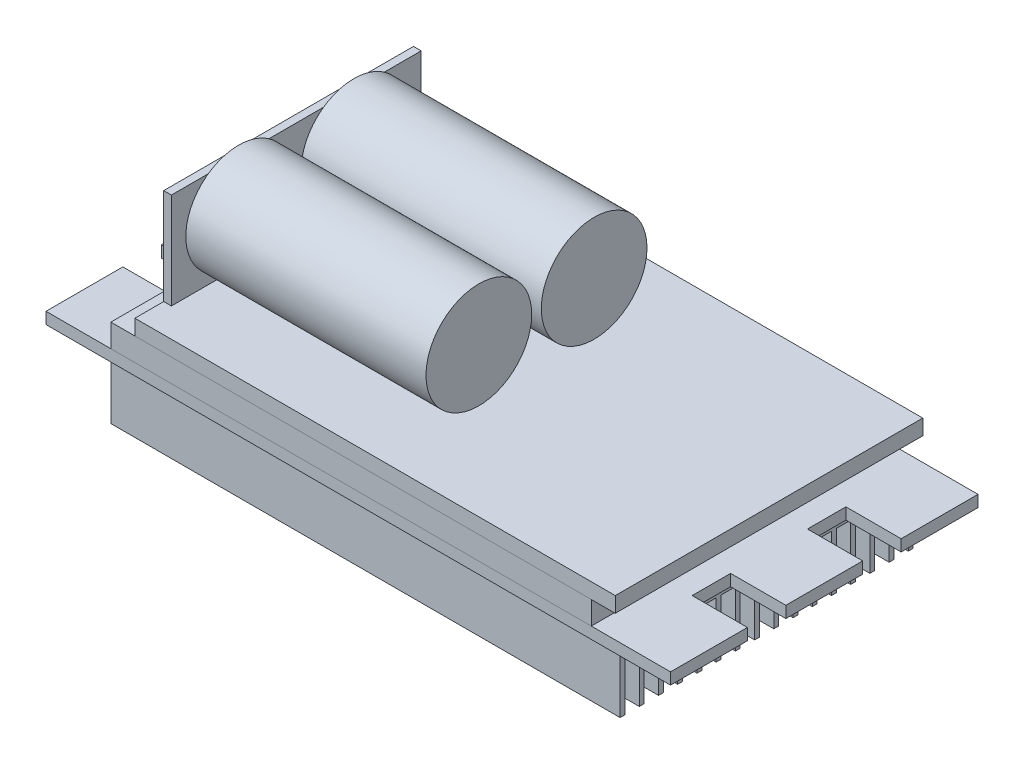
from build123d import *

# Parameters (mm, degrees)
BOSS_EXTRUDE1_DEPTH   = 1.2
SKETCH2_W             = 50
SKETCH2_H             = 32
BOSS_EXTRUDE2_DEPTH   = 2.4
SKETCH3_W             = 50
SKETCH3_H             = 32
BOSS_EXTRUDE3_DEPTH   = 1.6
SKETCH4_W             = 0.8
SKETCH4_H             = 26
BOSS_EXTRUDE4_DEPTH   = 10
SKETCH5_R             = 5.5
BOSS_EXTRUDE6_DEPTH   = 25
BOSS_EXTRUDE6_2_DEPTH = 25
SKETCH6_W             = 53
SKETCH6_H             = 30.5
BOSS_EXTRUDE7_DEPTH   = 6.3
CUT_EXTRUDE7_DEPTH    = 60


with BuildPart() as part:
    # Sketch1 → Boss-Extrude1 (new body)
    with BuildSketch(Plane(origin=(0, 0, 0), x_dir=(1, 0, 0), z_dir=(0, 1, 0))):
        Polygon((-26.75, 16), (-32.5, 16), (-32.5, 8), (-26.75, 8), (-26.75, 4), (-32.5, 4), (-32.5, -4), (-26.75, -4), (-26.75, -8), (-32.5, -8), (-32.5, -16), (-26.75, -16), (26.75, -16), (32.5, -16), (32.5, -8), (26.75, -8), (26.75, -4), (32.5, -4), (32.5, 4), (26.75, 4), (26.75, 8), (32.5, 8), (32.5, 16), (26.75, 16), align=None)
    extrude(amount=BOSS_EXTRUDE1_DEPTH)

    # Sketch6 → Boss-Extrude7 (add)
    with BuildSketch(Plane(origin=(0, 0, 0), x_dir=(-1, 0, 0), z_dir=(0, -1, 0))):
        Rectangle(SKETCH6_W, SKETCH6_H)
    extrude(amount=BOSS_EXTRUDE7_DEPTH)

    # Sketch8 → Cut-Extrude7 (cut, through all)
    with BuildSketch(Plane(origin=(26.5, 0, 0), x_dir=(0, 0, -1), z_dir=(1, 0, 0))):
        Polygon((-15.25, 0), (-15.25, -6.3), (-14.75, -6.3), (-14.75, -0.5), (-13.25, -0.5), (-13.25, -6.3), (-12.75, -6.3), (-12.75, -0.5), (-11.25, -0.5), (-11.25, -6.3), (-10.75, -6.3), (-10.75, -0.5), (-9.25, -0.5), (-9.25, -6.3), (-8.75, -6.3), (-8.75, -0.5), (-7.25, -0.5), (-7.25, -6.3), (-6.75, -6.3), (-6.75, -0.5), (-5.25, -0.5), (-5.25, -6.3), (-4.75, -6.3), (-4.75, -0.5), (-3.25, -0.5), (-3.25, -6.3), (-2.75, -6.3), (-2.75, -0.5), (-1.25, -0.5), (-1.25, -6.3), (-0.75, -6.3), (-0.75, -0.5), (0.75, -0.5), (0.75, -6.3), (1.25, -6.3), (1.25, -0.5), (2.75, -0.5), (2.75, -6.3), (3.25, -6.3), (3.25, -0.5), (4.75, -0.5), (4.75, -6.3), (5.25, -6.3), (5.25, -0.5), (6.75, -0.5), (6.75, -6.3), (7.25, -6.3), (7.25, -0.5), (8.75, -0.5), (8.75, -6.3), (9.25, -6.3), (9.25, -0.5), (10.75, -0.5), (10.75, -6.3), (11.25, -6.3), (11.25, -0.5), (12.75, -0.5), (12.75, -6.3), (13.25, -6.3), (13.25, -0.5), (14.75, -0.5), (14.75, -6.3), (15.25, -6.3), (15.25, 0), (23.612450935, 0), (23.612450935, -15.947306279), (-23.612450935, -15.947306279), (-23.612450935, 0), align=None)
    extrude(amount=-CUT_EXTRUDE7_DEPTH, mode=Mode.SUBTRACT)


with BuildPart() as body_2:
    # Sketch2 → Boss-Extrude2 (new body)
    with BuildSketch(Plane(origin=(0, 1.2, 0), x_dir=(1, 0, 0), z_dir=(0, 1, 0))):
        with Locations((-0.75, 0)):
            Rectangle(SKETCH2_W, SKETCH2_H)
    extrude(amount=BOSS_EXTRUDE2_DEPTH)


with BuildPart() as body_3:
    # Sketch3 → Boss-Extrude3 (new body)
    with BuildSketch(Plane(origin=(0, 3.6, 0), x_dir=(1, 0, 0), z_dir=(0, 1, 0))):
        with Locations((1.75, 0)):
            Rectangle(SKETCH3_W, SKETCH3_H)
    extrude(amount=BOSS_EXTRUDE3_DEPTH)

    # Sketch4 → Boss-Extrude4 (add)
    with BuildSketch(Plane(origin=(0, 5.2, 0), x_dir=(1, 0, 0), z_dir=(0, 1, 0))):
        with Locations((-22.85, 0)):
            Rectangle(SKETCH4_W, SKETCH4_H)
    extrude(amount=BOSS_EXTRUDE4_DEPTH)


with BuildPart() as body_4:
    # Sketch5 → Boss-Extrude6 (new body)
    with BuildSketch(Plane(origin=(-22.45, 0, 0), x_dir=(0, 0, -1), z_dir=(1, 0, 0))):
        with Locations((-6, 10.7)):
            Circle(SKETCH5_R)
    extrude(amount=BOSS_EXTRUDE6_DEPTH)


with BuildPart() as body_5:
    # Sketch5 → Boss-Extrude6 2 (new body)
    with BuildSketch(Plane(origin=(-22.45, 0, 0), x_dir=(0, 0, -1), z_dir=(1, 0, 0))):
        with Locations((6, 10.7)):
            Circle(SKETCH5_R)
    extrude(amount=BOSS_EXTRUDE6_2_DEPTH)


solid = Compound([part.part, body_2.part, body_3.part, body_4.part, body_5.part])
